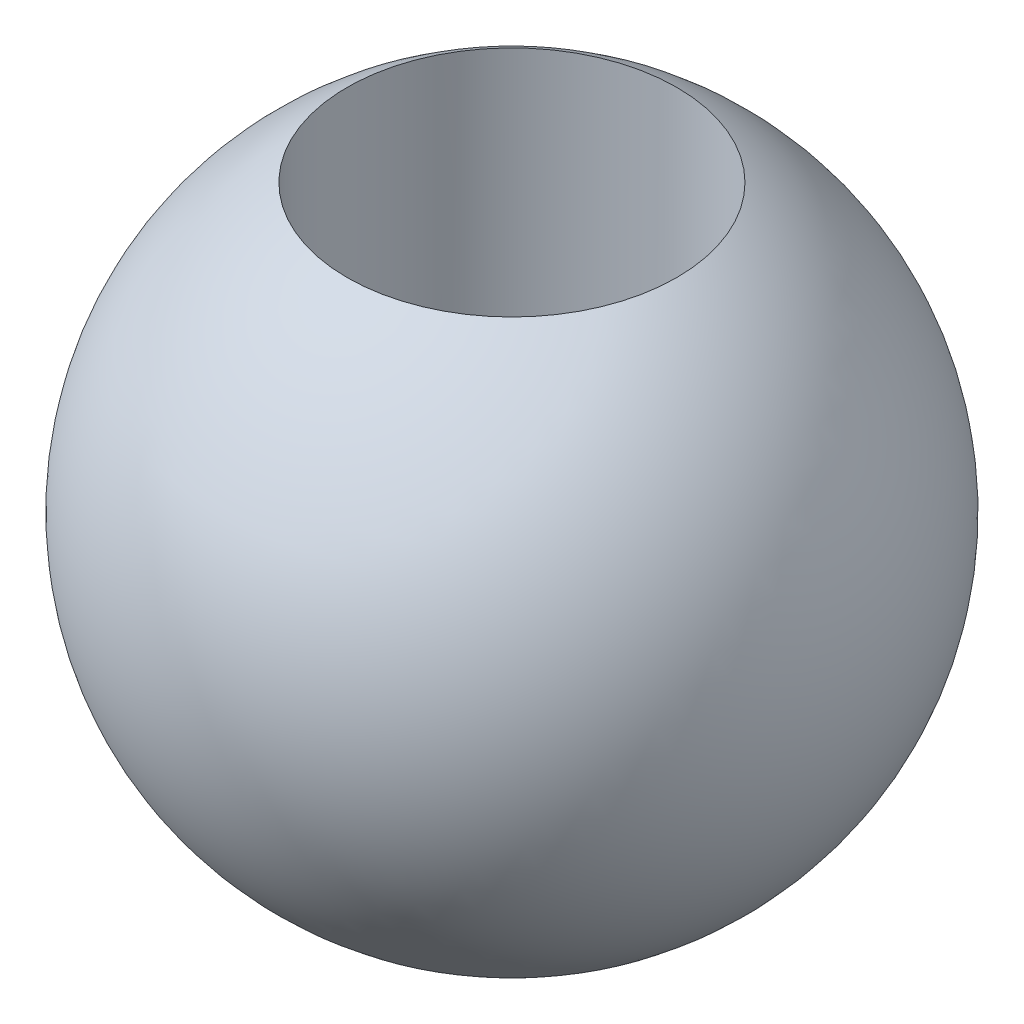
from build123d import *

# Parameters (mm, degrees)
SKETCH4_R          = 5
CUT_EXTRUDE1_DEPTH = 12.5


with BuildPart() as part:
    # Sketch1 → Revolve2 (revolve)
    with BuildSketch(Plane.XY):
        with BuildLine():
            Line((0, -10), (0, 10))
            ThreePointArc((0, 10), (10, 0), (0, -10))
        make_face()
    revolve(axis=Axis((0, 10, 0), (0, -1, 0)))

    # Sketch4 → Cut-Extrude1 (cut)
    with BuildSketch(Plane(origin=(0, 10, 0), x_dir=(1, 0, 0), z_dir=(0, 1, 0))):
        Circle(SKETCH4_R)
    extrude(amount=-CUT_EXTRUDE1_DEPTH, mode=Mode.SUBTRACT)


solid = part.part
